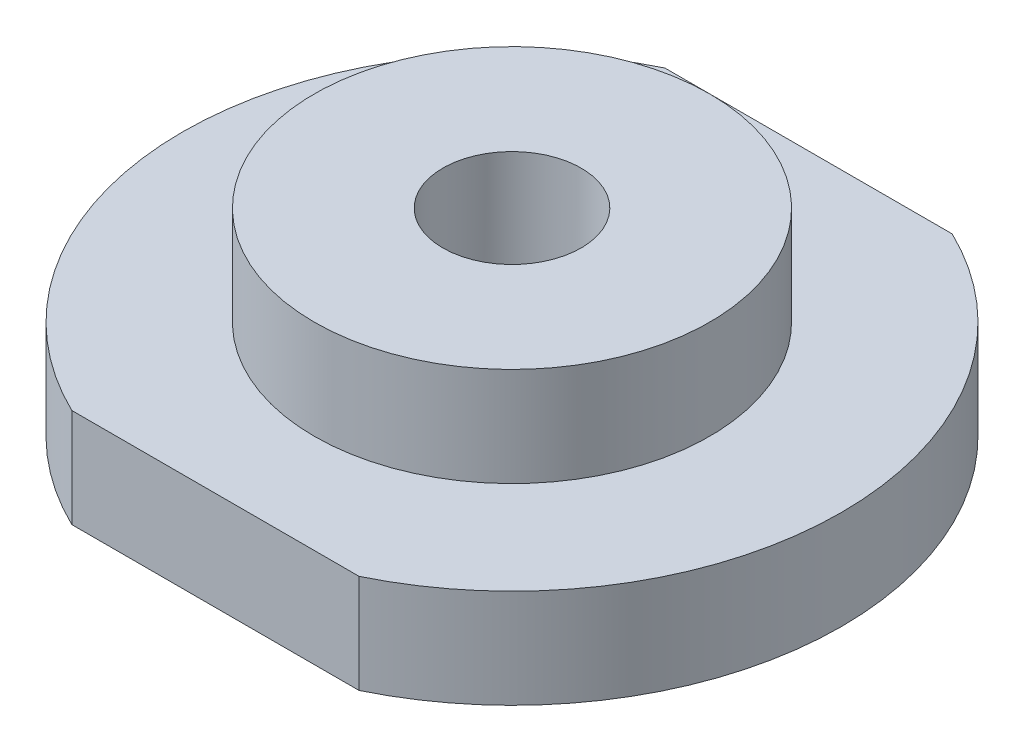
from build123d import *

# Parameters (mm, degrees)
SKETCH1_R           = 10
BOSS_EXTRUDE2_DEPTH = 8
SKETCH3_R           = 10
SKETCH3_R_2         = 6
CUT_EXTRUDE1_DEPTH  = 5
SKETCH4_R           = 2.1
CUT_EXTRUDE2_DEPTH  = 11
SKETCH5_R           = 6
CUT_EXTRUDE3_DEPTH  = 1.5
SKETCH6_R           = 6.5
CUT_EXTRUDE4_DEPTH  = 2
SKETCH7_R           = 6
CUT_EXTRUDE5_DEPTH  = 1
SKETCH8_R           = 6
CUT_EXTRUDE6_DEPTH  = 1
SKETCH9_R           = 6.5
BOSS_EXTRUDE3_DEPTH = 2
CUT_EXTRUDE7_DEPTH  = 10


with BuildPart() as part:
    # Sketch1 → Boss-Extrude2 (new body)
    with BuildSketch(Plane(origin=(0, 0, 0), x_dir=(1, 0, 0), z_dir=(0, 1, 0))):
        Circle(SKETCH1_R)
    extrude(amount=BOSS_EXTRUDE2_DEPTH)

    # Sketch3 → Cut-Extrude1 (cut)
    with BuildSketch(Plane(origin=(0, 8, 0), x_dir=(1, 0, 0), z_dir=(0, 1, 0))):
        Circle(SKETCH3_R)
        Circle(SKETCH3_R_2, mode=Mode.SUBTRACT)
    extrude(amount=-CUT_EXTRUDE1_DEPTH, mode=Mode.SUBTRACT)

    # Sketch4 → Cut-Extrude2 (cut)
    with BuildSketch(Plane(origin=(0, 8, 0), x_dir=(1, 0, 0), z_dir=(0, 1, 0))):
        Circle(SKETCH4_R)
    extrude(amount=-CUT_EXTRUDE2_DEPTH, mode=Mode.SUBTRACT)

    # Sketch5 → Cut-Extrude3 (cut)
    with BuildSketch(Plane.XZ):
        Circle(SKETCH5_R)
    extrude(amount=-CUT_EXTRUDE3_DEPTH, mode=Mode.SUBTRACT)

    # Sketch6 → Cut-Extrude4 (cut)
    with BuildSketch(Plane.XZ):
        Circle(SKETCH6_R)
    extrude(amount=-CUT_EXTRUDE4_DEPTH, mode=Mode.SUBTRACT)

    # Sketch7 → Cut-Extrude5 (cut)
    with BuildSketch(Plane(origin=(0, 8, 0), x_dir=(1, 0, 0), z_dir=(0, 1, 0))):
        Circle(SKETCH7_R)
    extrude(amount=-CUT_EXTRUDE5_DEPTH, mode=Mode.SUBTRACT)

    # Sketch8 → Cut-Extrude6 (cut)
    with BuildSketch(Plane(origin=(0, 7, 0), x_dir=(1, 0, 0), z_dir=(0, 1, 0))):
        Circle(SKETCH8_R)
    extrude(amount=-CUT_EXTRUDE6_DEPTH, mode=Mode.SUBTRACT)

    # Sketch9 → Boss-Extrude3 (add)
    with BuildSketch(Plane.XZ.offset(-2)):
        Circle(SKETCH9_R)
        Polygon((-3.6, -2.1), (0, -4.1), (3.6, -2.1), (3.6, 2.1), (0, 4.1), (-3.6, 2.1), align=None, mode=Mode.SUBTRACT)
    extrude(amount=BOSS_EXTRUDE3_DEPTH)

    # Sketch10 → Cut-Extrude7 (cut)
    with BuildSketch(Plane(origin=(0, 0, 0), x_dir=(-1, 0, 0), z_dir=(0, -1, 0))):
        with BuildLine():
            ThreePointArc((-4.358898944, -9), (0, -10), (4.358898944, -9))
            Line((4.358898944, -9), (-4.358898944, -9))
        make_face()
        with BuildLine():
            ThreePointArc((4.358898944, 9), (0, 10), (-4.358898944, 9))
            Line((-4.358898944, 9), (4.358898944, 9))
        make_face()
    extrude(amount=-CUT_EXTRUDE7_DEPTH, mode=Mode.SUBTRACT)


solid = part.part
